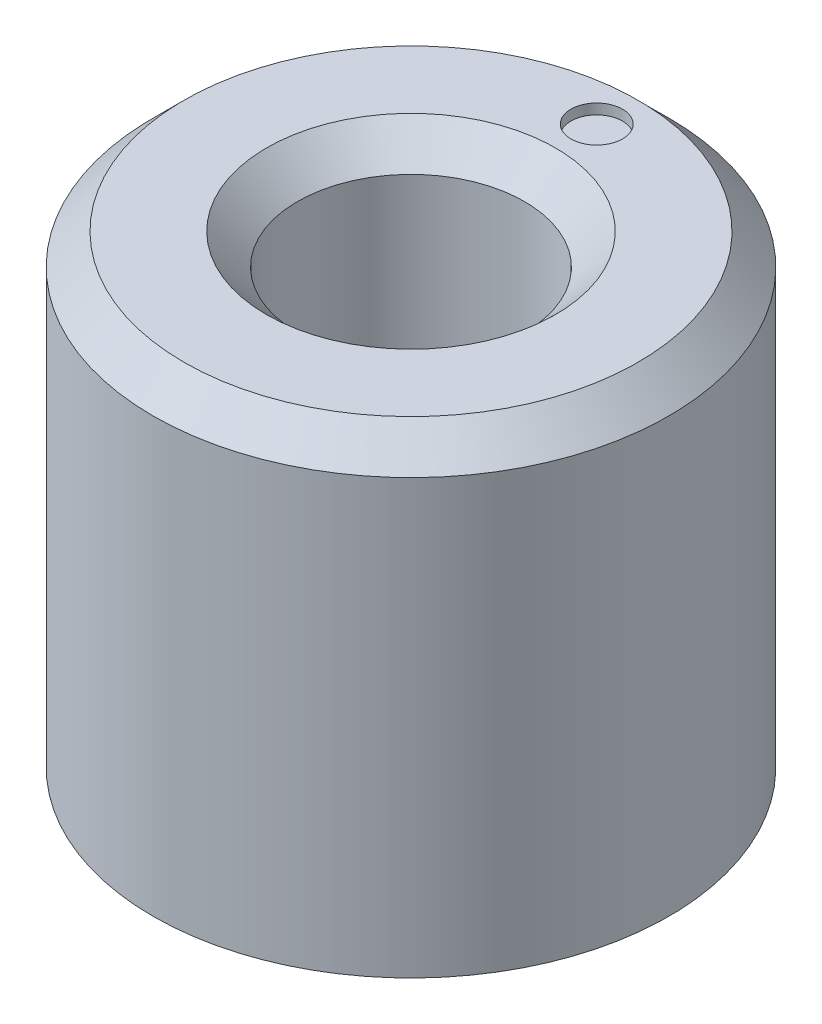
from build123d import *

# Parameters (mm, degrees)
SKETCH_1_R          = 5
EXTRUDE_1_DEPTH     = 9
SKETCH_2_R          = 2.2
CUT_EXTRUDE_1_DEPTH = 10
SKETCH_3_R          = 0.5
CUT_EXTRUDE_2_DEPTH = 0.2
CHAMFER_1_SIZE      = 0.6


with BuildPart() as part:
    # ｽｹｯﾁ1 → ﾎﾞｽ - 押し出し1 (new body)
    with BuildSketch(Plane(origin=(0, 0, 0), x_dir=(1, 0, 0), z_dir=(0, 1, 0))):
        Circle(SKETCH_1_R)
    extrude(amount=EXTRUDE_1_DEPTH)

    # ｽｹｯﾁ2 → ｶｯﾄ - 押し出し1 (cut, through all)
    with BuildSketch(Plane(origin=(0, 0, 0), x_dir=(1, 0, 0), z_dir=(0, 1, 0))):
        Circle(SKETCH_2_R)
    extrude(amount=CUT_EXTRUDE_1_DEPTH, mode=Mode.SUBTRACT)

    # ｽｹｯﾁ3 → ｶｯﾄ - 押し出し2 (cut)
    with BuildSketch(Plane(origin=(0, 9, 0), x_dir=(1, 0, 0), z_dir=(0, 1, 0))):
        with Locations((0, 3.6)):
            Circle(SKETCH_3_R)
    extrude(amount=-CUT_EXTRUDE_2_DEPTH, mode=Mode.SUBTRACT)

    # 面取り1
    chamfer_1_edges = [part.edges().sort_by_distance(p)[0] for p in [
        (-5, 9, 0),
        (-2.2, 9, 0),
    ]]
    chamfer(chamfer_1_edges, length=CHAMFER_1_SIZE)


solid = part.part
